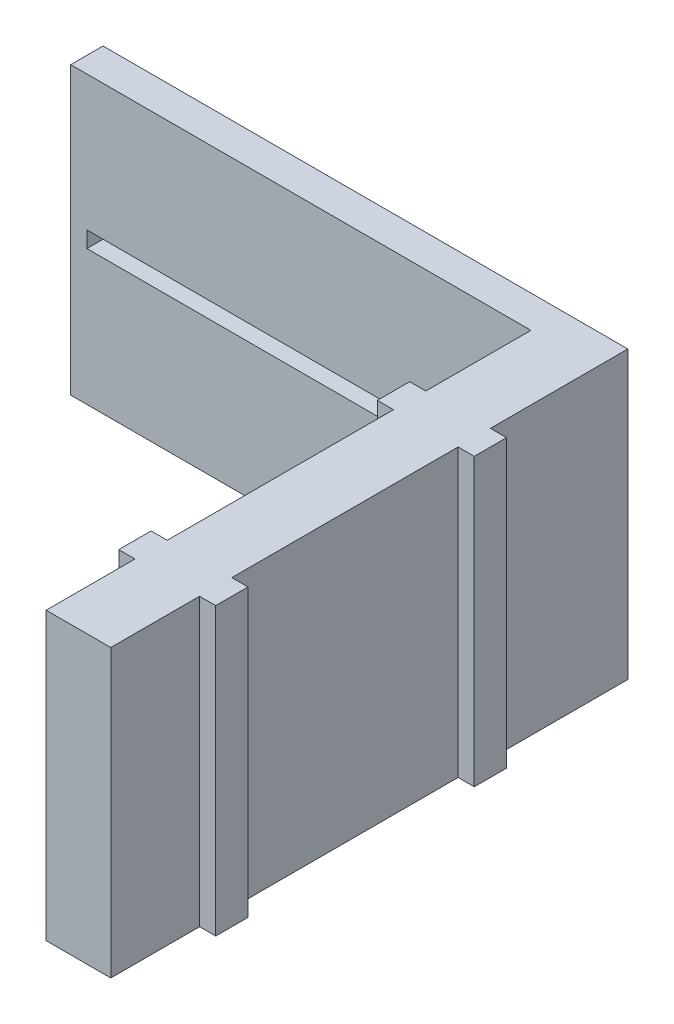
from build123d import *

# Parameters (mm, degrees)
SKETCH2_W           = 160
SKETCH2_H           = 88.569233124
BOSS_EXTRUDE1_DEPTH = 10
SKETCH3_W           = 10
SKETCH3_H           = 88.569233124
BOSS_EXTRUDE2_DEPTH = 152.4
SKETCH4_W           = 10
SKETCH4_H           = 5
CUT_EXTRUDE6_DEPTH  = 152.4
SKETCH4_2_W         = 10
SKETCH4_2_H         = 5
BOSS_EXTRUDE3_DEPTH = 5
SKETCH6_W           = 10
SKETCH6_H           = 88.569233124
BOSS_EXTRUDE4_DEPTH = 5


with BuildPart() as part:
    # Sketch2 → Boss-Extrude1 (new body)
    with BuildSketch(Plane(origin=(0, 0, 0), x_dir=(0, 0, -1), z_dir=(1, 0, 0))):
        Rectangle(SKETCH2_W, SKETCH2_H)
    boss_extrude1 = extrude(amount=BOSS_EXTRUDE1_DEPTH)

    # Sketch3 → Boss-Extrude2 (add)
    with BuildSketch(Plane.ZY):
        with Locations((-75, 0)):
            Rectangle(SKETCH3_W, SKETCH3_H)
    extrude(amount=BOSS_EXTRUDE2_DEPTH)

    # Sketch4 → Cut-Extrude6 (cut)
    with BuildSketch(Plane.ZY.offset(152.4)):
        with Locations((-75, 0)):
            Rectangle(SKETCH4_W, SKETCH4_H)
    extrude(amount=-CUT_EXTRUDE6_DEPTH, mode=Mode.SUBTRACT)

    # Sketch4_2 → Boss-Extrude3 (add)
    with BuildSketch(Plane.ZY.offset(152.4)):
        with Locations((-75, 0)):
            Rectangle(SKETCH4_2_W, SKETCH4_2_H)
    extrude(amount=-BOSS_EXTRUDE3_DEPTH)

    # Sketch6 → Boss-Extrude4 (add)
    with BuildSketch(Plane(origin=(10, 0, 0), x_dir=(0, 0, -1), z_dir=(1, 0, 0))):
        with Locations((32.47, 0)):
            Rectangle(SKETCH6_W, SKETCH6_H)
        with Locations((-47.53, 0)):
            Rectangle(SKETCH6_W, SKETCH6_H)
    boss_extrude4 = extrude(amount=BOSS_EXTRUDE4_DEPTH)

    # Mirror2: Boss-Extrude1, Boss-Extrude4 across plane
    add(boss_extrude1.mirror(Plane(origin=(0, 0, 0), x_dir=(0, 0, 1), z_dir=(1, 0, 0))))
    add(boss_extrude4.mirror(Plane(origin=(0, 0, 0), x_dir=(0, 0, 1), z_dir=(1, 0, 0))))


solid = part.part
